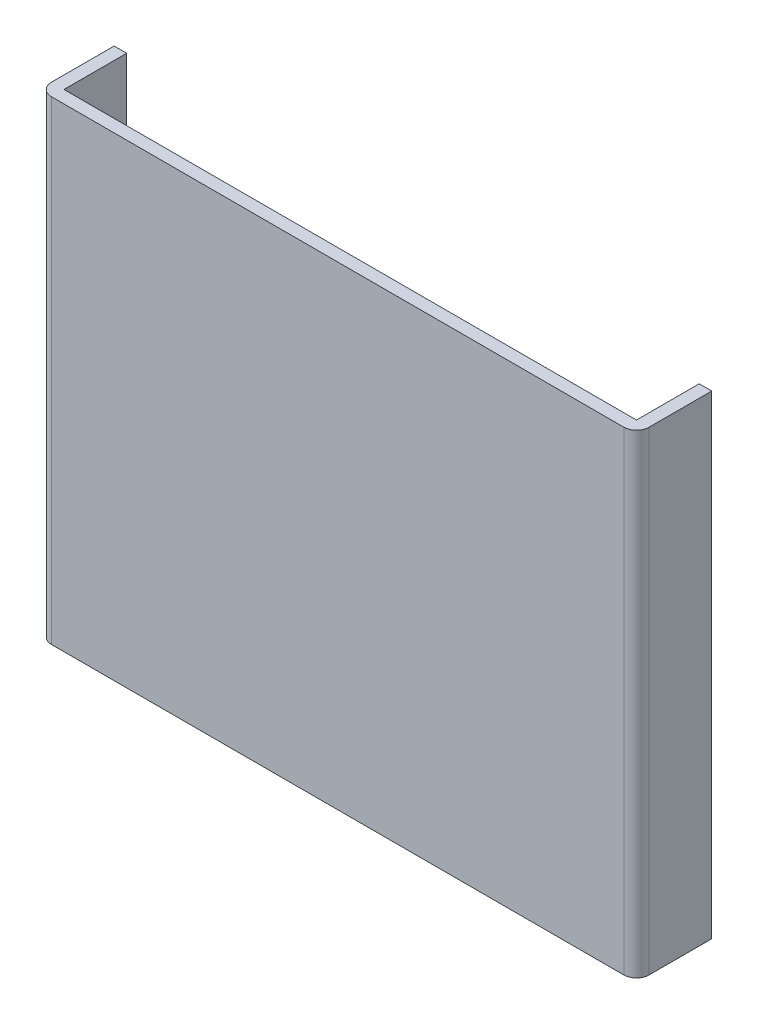
from build123d import *

# Parameters (mm, degrees)
BOSS_EXTRUDE1_DEPTH = 75.62
FILLET1_R           = 2


with BuildPart() as part:
    # Sketch1 → Boss-Extrude1 (new body)
    with BuildSketch(Plane(origin=(0, 0, 0), x_dir=(1, 0, 0), z_dir=(0, 1, 0))):
        Polygon((-18.601077114, -3.563509794), (-18.601077114, -15.563509794), (76.658922886, -15.563509794), (76.658922886, -3.563509794), (74.658922886, -3.563509794), (74.658922886, -13.563509794), (-16.601077114, -13.563509794), (-16.601077114, -3.563509794), align=None)
    extrude(amount=BOSS_EXTRUDE1_DEPTH)

    # Fillet1
    fillet1_edges = [part.edges().sort_by_distance(p)[0] for p in [
        (76.658922886, 37.81, 15.563509794),
        (-18.601077114, 37.81, 15.563509794),
    ]]
    fillet(fillet1_edges, radius=FILLET1_R)


solid = part.part
